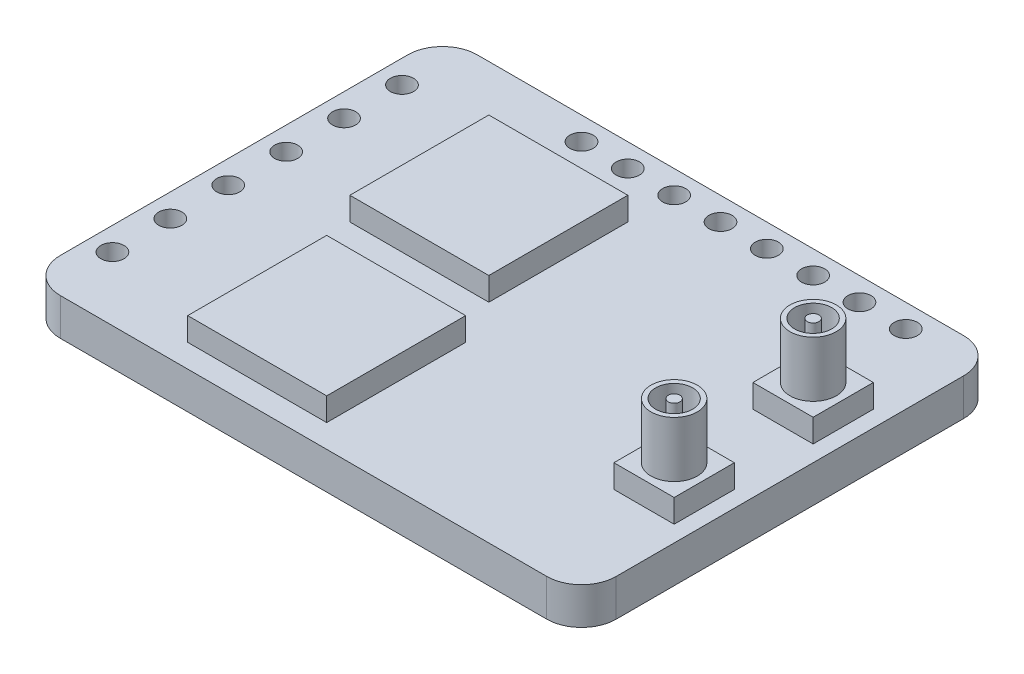
from build123d import *

# Parameters (mm, degrees)
SKETCH1_R             = 0.5
BOSS_EXTRUDE1_DEPTH   = 1.6
SKETCH2_W             = 6
SKETCH2_H             = 6
BOSS_EXTRUDE2_DEPTH   = 1
BOSS_EXTRUDE2_2_DEPTH = 1
SKETCH3_R             = 1
SKETCH3_R_2           = 0.8
BOSS_EXTRUDE3_DEPTH   = 3.4
SKETCH3_R_3           = 0.25
BOSS_EXTRUDE3_2_DEPTH = 3.4
BOSS_EXTRUDE3_3_DEPTH = 3.4
BOSS_EXTRUDE3_4_DEPTH = 3.4
SKETCH4_W             = 2.6
SKETCH4_H             = 2.6
BOSS_EXTRUDE4_DEPTH   = 1
BOSS_EXTRUDE4_2_DEPTH = 1


with BuildPart() as part:
    # Sketch1 → Boss-Extrude1 (new body)
    with BuildSketch(Plane(origin=(0, 0, 0), x_dir=(1, 0, 0), z_dir=(0, 1, 0))):
        with BuildLine():
            Line((-12, 7.5), (-12, -7.5))
            ThreePointArc((-12, -7.5), (-11.560660172, -8.560660172), (-10.5, -9))
            Line((-10.5, -9), (10.5, -9))
            ThreePointArc((10.5, -9), (11.560660172, -8.560660172), (12, -7.5))
            Line((12, -7.5), (12, 7.5))
            ThreePointArc((12, 7.5), (11.560660172, 8.560660172), (10.5, 9))
            Line((10.5, 9), (-10.5, 9))
            ThreePointArc((-10.5, 9), (-11.560660172, 8.560660172), (-12, 7.5))
        make_face()
        with Locations((-11, 6.25)):
            Circle(SKETCH1_R, mode=Mode.SUBTRACT)
        with Locations((-11, 3.75)):
            Circle(SKETCH1_R, mode=Mode.SUBTRACT)
        with Locations((-11, 1.25)):
            Circle(SKETCH1_R, mode=Mode.SUBTRACT)
        with Locations((-11, -1.25)):
            Circle(SKETCH1_R, mode=Mode.SUBTRACT)
        with Locations((-11, -3.75)):
            Circle(SKETCH1_R, mode=Mode.SUBTRACT)
        with Locations((-11, -6.25)):
            Circle(SKETCH1_R, mode=Mode.SUBTRACT)
        with Locations((9, 8)):
            Circle(SKETCH1_R, mode=Mode.SUBTRACT)
        with Locations((7, 8)):
            Circle(SKETCH1_R, mode=Mode.SUBTRACT)
        with Locations((5, 8)):
            Circle(SKETCH1_R, mode=Mode.SUBTRACT)
        with Locations((3, 8)):
            Circle(SKETCH1_R, mode=Mode.SUBTRACT)
        with Locations((1, 8)):
            Circle(SKETCH1_R, mode=Mode.SUBTRACT)
        with Locations((-1, 8)):
            Circle(SKETCH1_R, mode=Mode.SUBTRACT)
        with Locations((-3, 8)):
            Circle(SKETCH1_R, mode=Mode.SUBTRACT)
        with Locations((-5, 8)):
            Circle(SKETCH1_R, mode=Mode.SUBTRACT)
    extrude(amount=BOSS_EXTRUDE1_DEPTH)


with BuildPart() as body_2:
    # Sketch2 → Boss-Extrude2 (new body)
    with BuildSketch(Plane(origin=(0, 1.6, 0), x_dir=(1, 0, 0), z_dir=(0, 1, 0))):
        with Locations((-4, 3)):
            Rectangle(SKETCH2_W, SKETCH2_H)
    extrude(amount=BOSS_EXTRUDE2_DEPTH)


with BuildPart() as body_3:
    # Sketch2 → Boss-Extrude2 2 (new body)
    with BuildSketch(Plane(origin=(0, 1.6, 0), x_dir=(1, 0, 0), z_dir=(0, 1, 0))):
        with Locations((-3, -5)):
            Rectangle(SKETCH2_W, SKETCH2_H)
    extrude(amount=BOSS_EXTRUDE2_2_DEPTH)


with BuildPart() as body_4:
    # Sketch3 → Boss-Extrude3 (new body)
    with BuildSketch(Plane(origin=(0, 1.6, 0), x_dir=(1, 0, 0), z_dir=(0, 1, 0))):
        with Locations((10, -3)):
            Circle(SKETCH3_R)
        with Locations((10, -3)):
            Circle(SKETCH3_R_2, mode=Mode.SUBTRACT)
    extrude(amount=BOSS_EXTRUDE3_DEPTH)


with BuildPart() as body_5:
    # Sketch3 → Boss-Extrude3 2 (new body)
    with BuildSketch(Plane(origin=(0, 1.6, 0), x_dir=(1, 0, 0), z_dir=(0, 1, 0))):
        with Locations((10, -3)):
            Circle(SKETCH3_R_3)
    extrude(amount=BOSS_EXTRUDE3_2_DEPTH)


with BuildPart() as body_6:
    # Sketch3 → Boss-Extrude3 3 (new body)
    with BuildSketch(Plane(origin=(0, 1.6, 0), x_dir=(1, 0, 0), z_dir=(0, 1, 0))):
        with Locations((10, 3)):
            Circle(SKETCH3_R)
        with Locations((10, 3)):
            Circle(SKETCH3_R_2, mode=Mode.SUBTRACT)
    extrude(amount=BOSS_EXTRUDE3_3_DEPTH)


with BuildPart() as body_7:
    # Sketch3 → Boss-Extrude3 4 (new body)
    with BuildSketch(Plane(origin=(0, 1.6, 0), x_dir=(1, 0, 0), z_dir=(0, 1, 0))):
        with Locations((10, 3)):
            Circle(SKETCH3_R_3)
    extrude(amount=BOSS_EXTRUDE3_4_DEPTH)


with BuildPart() as body_8:
    # Sketch4 → Boss-Extrude4 (new body)
    with BuildSketch(Plane(origin=(0, 1.6, 0), x_dir=(1, 0, 0), z_dir=(0, 1, 0))):
        with Locations((10, 3)):
            Rectangle(SKETCH4_W, SKETCH4_H)
    extrude(amount=BOSS_EXTRUDE4_DEPTH)


with BuildPart() as body_9:
    # Sketch4 → Boss-Extrude4 2 (new body)
    with BuildSketch(Plane(origin=(0, 1.6, 0), x_dir=(1, 0, 0), z_dir=(0, 1, 0))):
        with Locations((10, -3)):
            Rectangle(SKETCH4_W, SKETCH4_H)
    extrude(amount=BOSS_EXTRUDE4_2_DEPTH)

    # Combine3: union body 4, body 5
    add(body_4.part)
    add(body_5.part)


with BuildPart() as body_6_1:
    add(body_6.part)

    # Combine2: union body 8, body 7
    add(body_8.part)
    add(body_7.part)


solid = Compound([part.part, body_2.part, body_3.part, body_9.part, body_6_1.part])
